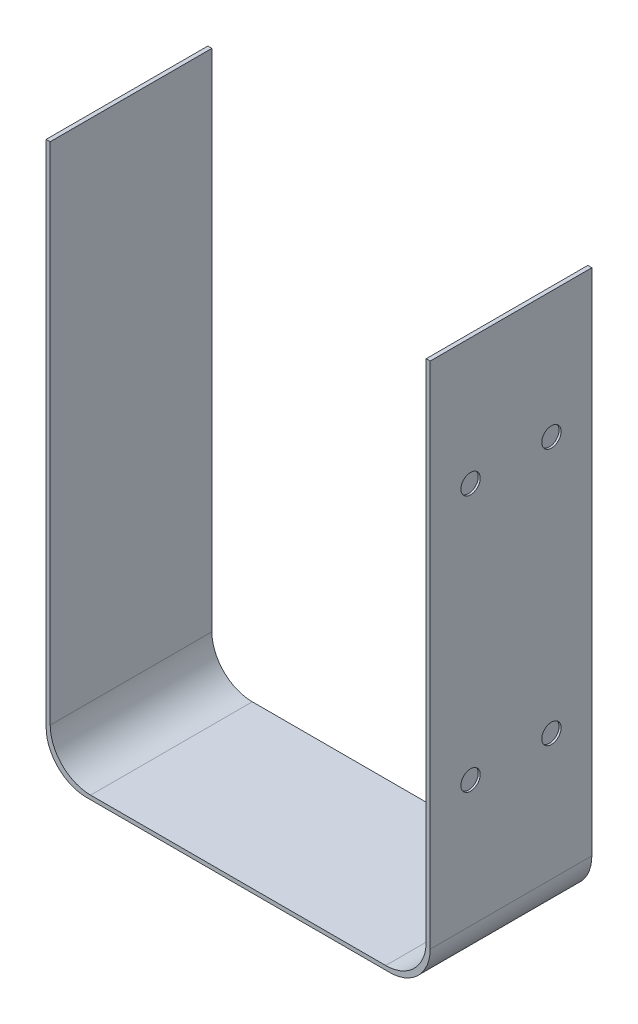
from build123d import *

# Parameters (mm, degrees)
DODANIE_WYCI_GNI_CIE1_DEPTH = 8
SZKIC2_R                    = 0.478785513
WYTNIJ_WYCI_GNI_CIE1_DEPTH  = 0.1
SZKIC3_R                    = 0.5
WYTNIJ_WYCI_GNI_CIE2_DEPTH  = 0.1


with BuildPart() as part:
    # Szkic1 → Dodanie-wyciągnięcie1 (new body)
    with BuildSketch(Plane.XY):
        with BuildLine():
            Line((-56.651560295, 21.778571429), (-56.851560295, 21.778571429))
            Line((-56.851560295, 21.778571429), (-56.851560295, -3.421428571))
            ThreePointArc((-56.851560295, -3.421428571), (-56.265773857, -4.835642134), (-54.851560295, -5.421428571))
            Line((-54.851560295, -5.421428571), (-39.851560295, -5.421428571))
            ThreePointArc((-39.851560295, -5.421428571), (-38.437346732, -4.835642134), (-37.851560295, -3.421428571))
            Line((-37.851560295, -3.421428571), (-37.851560295, 21.778571429))
            Line((-37.851560295, 21.778571429), (-38.051560295, 21.778571429))
            Line((-38.051560295, 21.778571429), (-38.051560295, -3.221428571))
            ThreePointArc((-38.051560295, -3.221428571), (-38.637346732, -4.635642134), (-40.051560295, -5.221428571))
            Line((-40.051560295, -5.221428571), (-54.651560295, -5.221428571))
            ThreePointArc((-54.651560295, -5.221428571), (-56.065773857, -4.635642134), (-56.651560295, -3.221428571))
            Line((-56.651560295, -3.221428571), (-56.651560295, 21.778571429))
        make_face()
    extrude(amount=DODANIE_WYCI_GNI_CIE1_DEPTH)

    # Szkic2 → Wytnij-wyciągnięcie1 (cut)
    with BuildSketch(Plane(origin=(-37.851560295, 0, 0), x_dir=(0, 0, -1), z_dir=(1, 0, 0))):
        with Locations((-6, 15.528571429)):
            Circle(SZKIC2_R)
        with Locations((-2, 15.528571429)):
            Circle(SZKIC2_R)
        with Locations((-2, 2.828571429)):
            Circle(SZKIC2_R)
        with Locations((-6, 2.828571429)):
            Circle(SZKIC2_R)
    extrude(amount=-WYTNIJ_WYCI_GNI_CIE1_DEPTH, mode=Mode.SUBTRACT)

    # Szkic3 → Wytnij-wyciągnięcie2 (cut)
    with BuildSketch(Plane.ZY.offset(56.851560295)):
        with Locations((6, 15.528571429)):
            Circle(SZKIC3_R)
        with Locations((2, 15.528571429)):
            Circle(SZKIC3_R)
        with Locations((2, 2.828571429)):
            Circle(SZKIC3_R)
        with Locations((6, 2.828571429)):
            Circle(SZKIC3_R)
    extrude(amount=-WYTNIJ_WYCI_GNI_CIE2_DEPTH, mode=Mode.SUBTRACT)


solid = part.part
